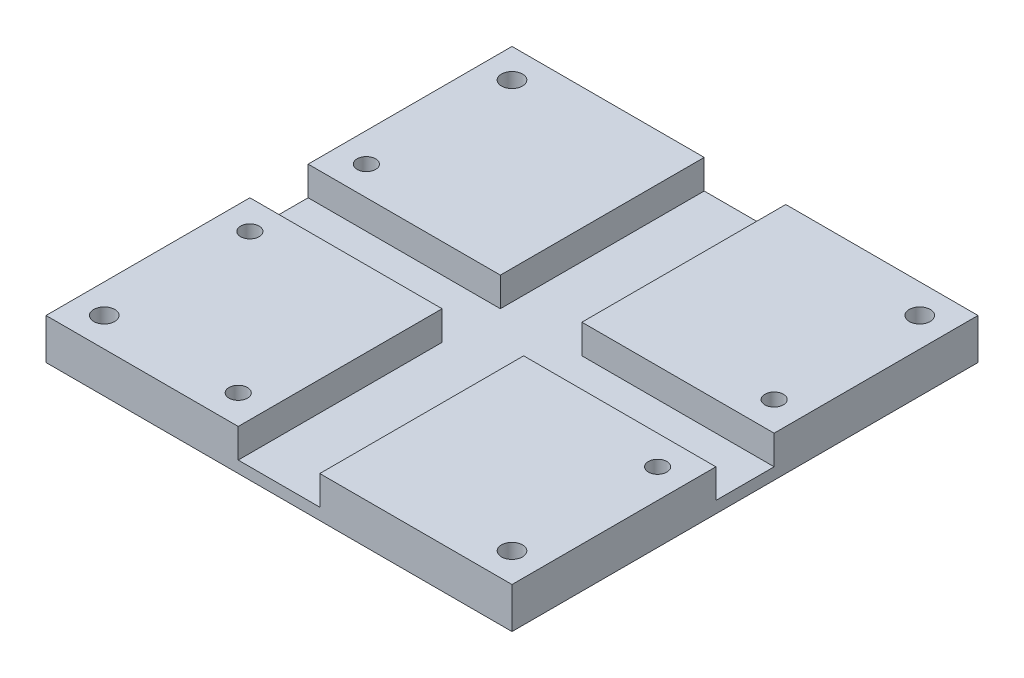
from build123d import *

# Parameters (mm, degrees)
SKETCH1_W                    = 80
SKETCH1_H                    = 80
PCB_DEPTH                    = 2
SKETCH7_W                    = 33
SKETCH7_H                    = 35
LIPO_ADAFRUIT_CHARGERS_DEPTH = 5
LPATTERN2_COUNT              = 2
LPATTERN2_PITCH              = 47
LPATTERN2_COUNT_DIR2         = 2
LPATTERN2_PITCH_DIR2         = 45
SKETCH4_R                    = 1.8
ATTACHMENT_HOLES_DEPTH       = 6
ATTACHMENT_HOLES_DEPTH_BACK  = 3
SKETCH8_R                    = 1.5875
CUT_EXTRUDE1_DEPTH           = 8
LPATTERN3_COUNT              = 2
LPATTERN3_PITCH              = 70
LPATTERN3_COUNT_DIR2         = 2
LPATTERN3_PITCH_DIR2         = 20
SKETCH9_R                    = 1.5875
CUT_EXTRUDE2_DEPTH           = 8


with BuildPart() as part:
    # Sketch1 → PCB (new body)
    with BuildSketch(Plane(origin=(0, 0, 0), x_dir=(1, 0, 0), z_dir=(0, 1, 0))):
        with Locations((40, 40)):
            Rectangle(SKETCH1_W, SKETCH1_H)
    extrude(amount=PCB_DEPTH)

    # Sketch7 → LiPo Adafruit Chargers (add)
    with BuildSketch(Plane(origin=(0, 2, 0), x_dir=(1, 0, 0), z_dir=(0, 1, 0))):
        with Locations((63.5, 17.5)):
            Rectangle(SKETCH7_W, SKETCH7_H)
    lipo_adafruit_chargers = extrude(amount=LIPO_ADAFRUIT_CHARGERS_DEPTH)

    # LPattern2: LiPo Adafruit Chargers 2 × 2
    with Locations(*[(-i * LPATTERN2_PITCH, 0, -j * LPATTERN2_PITCH_DIR2) for i in range(LPATTERN2_COUNT) for j in range(LPATTERN2_COUNT_DIR2) if (i, j) != (0, 0)]):
        add(lipo_adafruit_chargers)

    # Sketch4 → Attachment holes (cut, two sides)
    with BuildSketch(Plane(origin=(0, 2, 0), x_dir=(1, 0, 0), z_dir=(0, 1, 0))) as attachment_holes_sk:
        with Locations((5, 75)):
            Circle(SKETCH4_R)
        with Locations((75, 75)):
            Circle(SKETCH4_R)
        with Locations((75, 5)):
            Circle(SKETCH4_R)
        with Locations((5, 5)):
            Circle(SKETCH4_R)
    extrude(amount=ATTACHMENT_HOLES_DEPTH, mode=Mode.SUBTRACT)
    extrude(attachment_holes_sk.sketch, amount=-ATTACHMENT_HOLES_DEPTH_BACK, mode=Mode.SUBTRACT)

    # Sketch8 → Cut-Extrude1 (cut, through all)
    with BuildSketch(Plane(origin=(0, 7, 0), x_dir=(1, 0, 0), z_dir=(0, 1, 0))):
        with Locations((5, 30)):
            Circle(SKETCH8_R)
    cut_extrude1 = extrude(amount=-CUT_EXTRUDE1_DEPTH, mode=Mode.SUBTRACT)

    # LPattern3: Cut-Extrude1 2 × 2
    with Locations(*[(i * LPATTERN3_PITCH, 0, -j * LPATTERN3_PITCH_DIR2) for i in range(LPATTERN3_COUNT) for j in range(LPATTERN3_COUNT_DIR2) if (i, j) != (0, 0)]):
        add(cut_extrude1, mode=Mode.SUBTRACT)

    # Sketch9 → Cut-Extrude2 (cut, through all)
    with BuildSketch(Plane(origin=(0, 7, 0), x_dir=(1, 0, 0), z_dir=(0, 1, 0))):
        with Locations((28, 5)):
            Circle(SKETCH9_R)
    extrude(amount=-CUT_EXTRUDE2_DEPTH, mode=Mode.SUBTRACT)


solid = part.part
